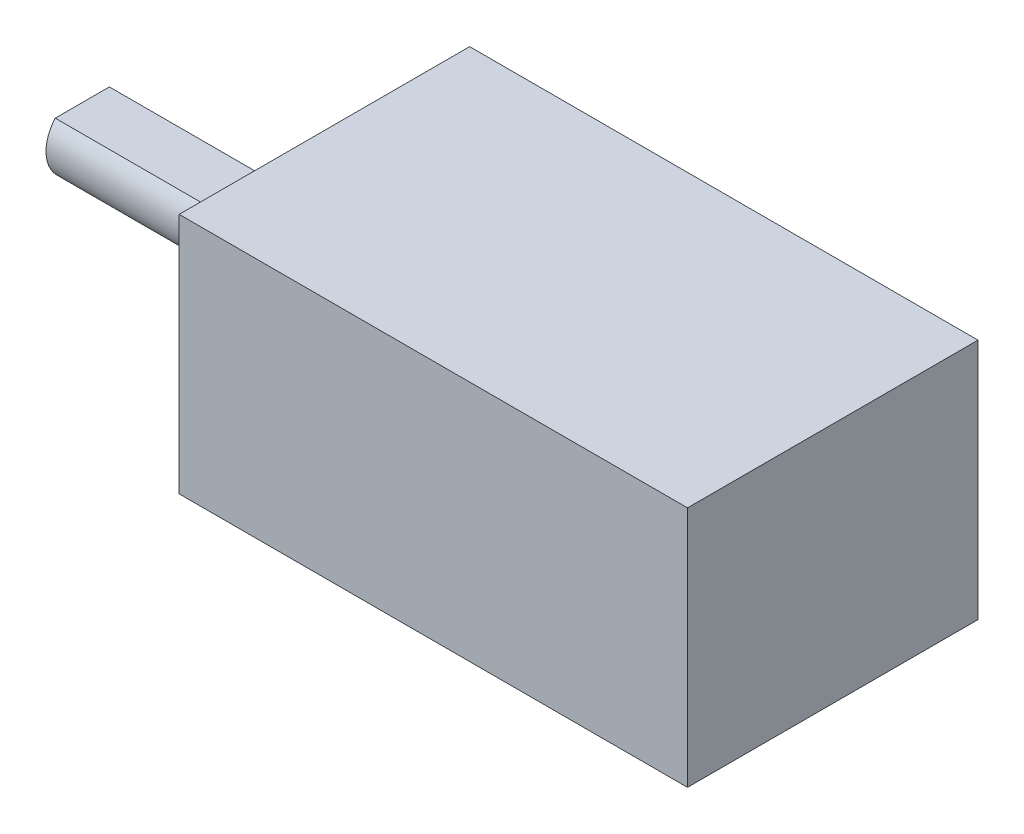
from build123d import *

# Parameters (mm, degrees)
SKETCH1_W           = 21
SKETCH1_H           = 12
BOSS_EXTRUDE1_DEPTH = 10
BOSS_EXTRUDE2_DEPTH = 10


with BuildPart() as part:
    # Sketch1 → Boss-Extrude1 (new body)
    with BuildSketch(Plane(origin=(0, 0, 0), x_dir=(1, 0, 0), z_dir=(0, 1, 0))):
        with Locations((10.5, 6)):
            Rectangle(SKETCH1_W, SKETCH1_H)
    extrude(amount=BOSS_EXTRUDE1_DEPTH)

    # Sketch2 → Boss-Extrude2 (add)
    with BuildSketch(Plane.ZY):
        with BuildLine():
            Line((-7.118033989, 6), (-4.881966011, 6))
            ThreePointArc((-4.881966011, 6), (-6, 3.5), (-7.118033989, 6))
        make_face()
    extrude(amount=BOSS_EXTRUDE2_DEPTH)


solid = part.part
